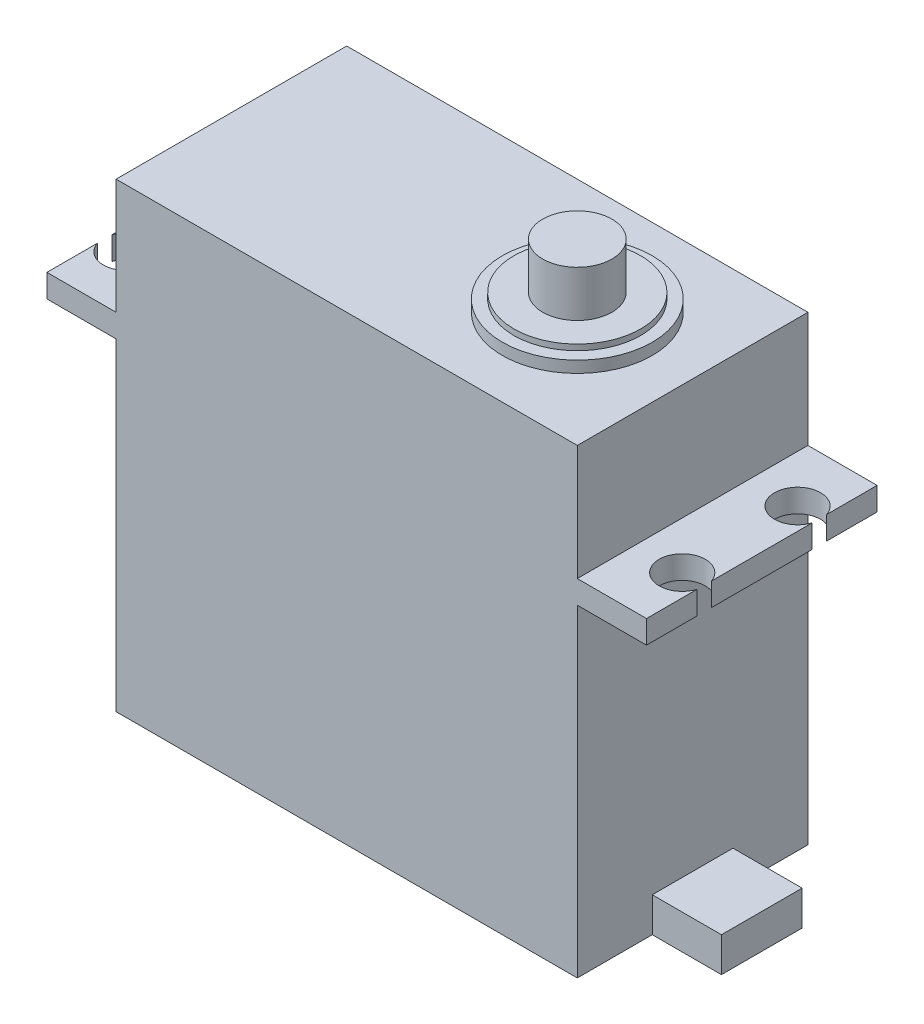
from build123d import *

# Parameters (mm, degrees)
SKETCH_1_W          = 40
SKETCH_1_H          = 20
EXTRUDE_1_DEPTH     = 40
SKETCH_2_W          = 20
SKETCH_2_H          = 2
SKETCH_2_W_2        = 7
SKETCH_2_H_2        = 3
EXTRUDE_2_DEPTH     = 6
SKETCH_3_W          = 20
SKETCH_3_H          = 2
EXTRUDE_3_DEPTH     = 6
SKETCH_4_R          = 2
CUT_EXTRUDE_2_DEPTH = 6
SKETCH_5_R          = 6.5
EXTRUDE_4_DEPTH     = 1
SKETCH_6_R          = 5.5
EXTRUDE_5_DEPTH     = 0.5
SKETCH_7_R          = 3
EXTRUDE_6_DEPTH     = 4


with BuildPart() as part:
    # 草图1 → 凸台-拉伸1 (new body)
    with BuildSketch(Plane(origin=(0, 0, 0), x_dir=(1, 0, 0), z_dir=(0, 1, 0))):
        Rectangle(SKETCH_1_W, SKETCH_1_H)
    extrude(amount=EXTRUDE_1_DEPTH)

    # 草图2 → 凸台-拉伸2 (add)
    with BuildSketch(Plane(origin=(20, 0, 0), x_dir=(0, 0, -1), z_dir=(1, 0, 0))):
        with Locations((0, 29)):
            Rectangle(SKETCH_2_W, SKETCH_2_H)
        with Locations((0, 1.5)):
            Rectangle(SKETCH_2_W_2, SKETCH_2_H_2)
    extrude(amount=EXTRUDE_2_DEPTH)

    # 草图3 → 凸台-拉伸3 (add)
    with BuildSketch(Plane.ZY.offset(20)):
        with Locations((0, 29)):
            Rectangle(SKETCH_3_W, SKETCH_3_H)
    extrude(amount=EXTRUDE_3_DEPTH)

    # 草图4 → 切除-拉伸2 (cut)
    with BuildSketch(Plane(origin=(0, 30, 0), x_dir=(1, 0, 0), z_dir=(0, 1, 0))):
        with Locations((24.1, 5)):
            Circle(SKETCH_4_R)
        with Locations((24.1, -5)):
            Circle(SKETCH_4_R)
        with Locations((-24.1, 5)):
            Circle(SKETCH_4_R)
        with Locations((-24.1, -5)):
            Circle(SKETCH_4_R)
    extrude(amount=-CUT_EXTRUDE_2_DEPTH, mode=Mode.SUBTRACT)

    # 草图5 → 凸台-拉伸4 (add)
    with BuildSketch(Plane(origin=(0, 40, 0), x_dir=(1, 0, 0), z_dir=(0, 1, 0))):
        with Locations((10, 0)):
            Circle(SKETCH_5_R)
    extrude(amount=EXTRUDE_4_DEPTH)

    # 草图6 → 凸台-拉伸5 (add)
    with BuildSketch(Plane(origin=(0, 41, 0), x_dir=(1, 0, 0), z_dir=(0, 1, 0))):
        with Locations((10, 0)):
            Circle(SKETCH_6_R)
    extrude(amount=EXTRUDE_5_DEPTH)

    # 草图7 → 凸台-拉伸6 (add)
    with BuildSketch(Plane(origin=(0, 41.5, 0), x_dir=(1, 0, 0), z_dir=(0, 1, 0))):
        with Locations((10, 0)):
            Circle(SKETCH_7_R)
    extrude(amount=EXTRUDE_6_DEPTH)


solid = part.part
